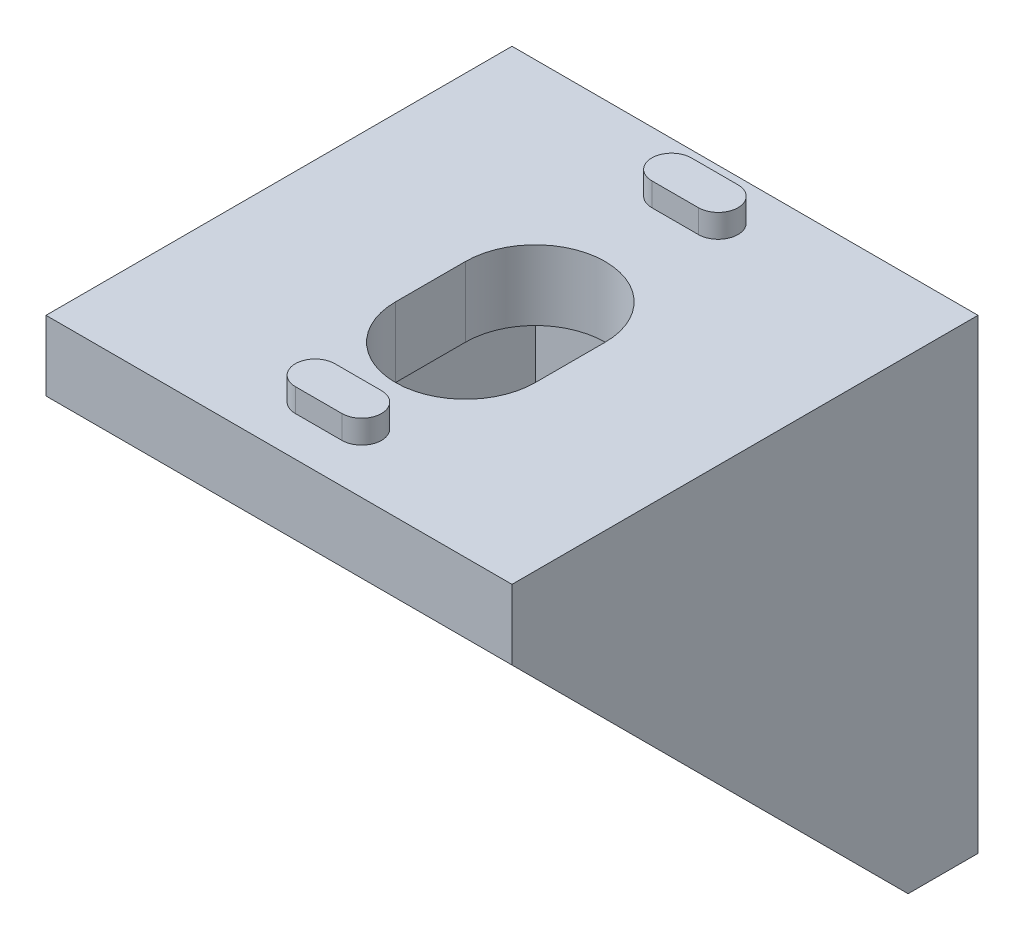
from build123d import *

# Parameters (mm, degrees)
BOSS_EXTRUDE1_DEPTH = 10
SKETCH2_W           = 17
SKETCH2_H           = 17
CUT_EXTRUDE1_DEPTH  = 6
CUT_EXTRUDE2_DEPTH  = 3
BOSS_EXTRUDE2_DEPTH = 1


with BuildPart() as part:
    # Sketch1 → Boss-Extrude1 (new body, symmetric)
    with BuildSketch(Plane(origin=(0, 0, 0), x_dir=(0, 0, -1), z_dir=(1, 0, 0))):
        Polygon((0, 0), (-20, 0), (-20, -3), (-11.5, -11.5), (-3, -20), (0, -20), align=None)
    extrude(amount=BOSS_EXTRUDE1_DEPTH, both=True)

    # Sketch2 → Cut-Extrude1 (cut, symmetric)
    with BuildSketch(Plane(origin=(0, 0, 0), x_dir=(0, 0, -1), z_dir=(1, 0, 0))):
        with Locations((-11.5, -11.5)):
            Rectangle(SKETCH2_W, SKETCH2_H)
    extrude(amount=CUT_EXTRUDE1_DEPTH, both=True, mode=Mode.SUBTRACT)

    # Sketch3 → Cut-Extrude2 (cut)
    with BuildSketch(Plane.XY.offset(3)):
        with BuildLine():
            Line((-3, -9), (-3, -12))
            ThreePointArc((-3, -12), (0, -15), (3, -12))
            Line((3, -12), (3, -9))
            ThreePointArc((3, -9), (0, -6), (-3, -9))
        make_face()
    cut_extrude2 = extrude(amount=-CUT_EXTRUDE2_DEPTH, mode=Mode.SUBTRACT)

    # Sketch4 → Boss-Extrude2 (add)
    with BuildSketch(Plane(origin=(0, 0, 0), x_dir=(-1, 0, 0), z_dir=(0, 0, -1))):
        with BuildLine():
            Line((-1, -3), (1, -3))
            ThreePointArc((1, -3), (1.85, -2.15), (1, -1.3))
            Line((1, -1.3), (-1, -1.3))
            ThreePointArc((-1, -1.3), (-1.85, -2.15), (-1, -3))
        make_face()
        with BuildLine():
            Line((-1, -18.3), (1, -18.3))
            ThreePointArc((1, -18.3), (1.85, -17.45), (1, -16.6))
            Line((1, -16.6), (-1, -16.6))
            ThreePointArc((-1, -16.6), (-1.85, -17.45), (-1, -18.3))
        make_face()
    boss_extrude2 = extrude(amount=BOSS_EXTRUDE2_DEPTH)

    # Mirror1: Cut-Extrude2, Boss-Extrude2 across plane
    add(cut_extrude2.mirror(Plane(origin=(0, 0, 0), x_dir=(0, -0.707106781, 0.707106781), z_dir=(0, 0.707106781, 0.707106781))), mode=Mode.SUBTRACT)
    add(boss_extrude2.mirror(Plane(origin=(0, 0, 0), x_dir=(0, -0.707106781, 0.707106781), z_dir=(0, 0.707106781, 0.707106781))))


solid = part.part
